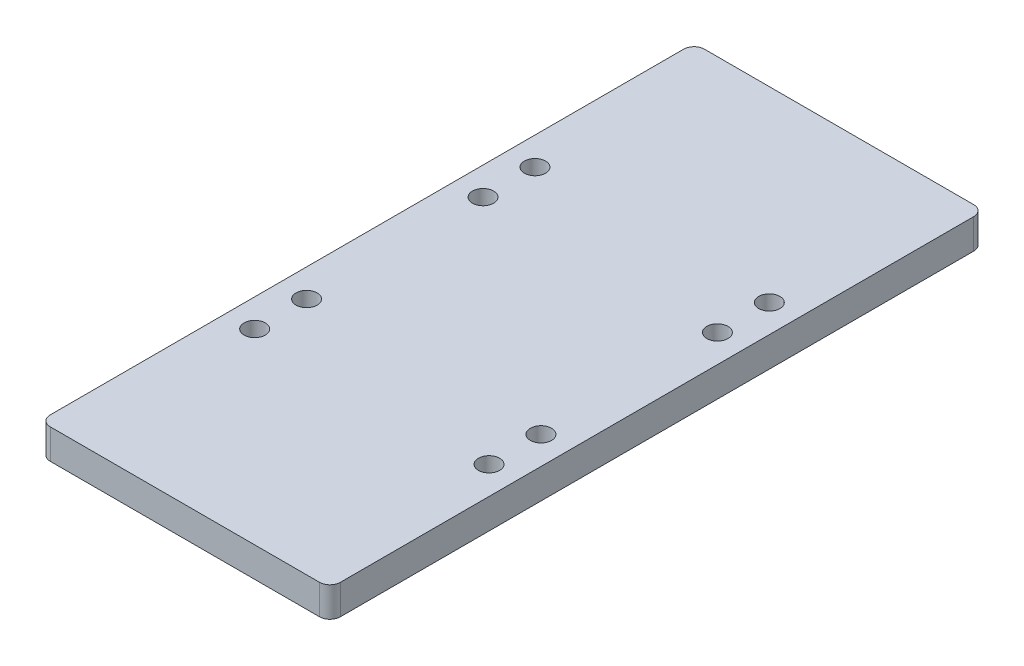
from build123d import *

# Parameters (mm, degrees)
SKETCH1_W                  = 70.946
SKETCH1_H                  = 160
BOSS_EXTRUDE1_DEPTH        = 7.3152
F_6_0_204_DIAMETER_HOLE1_D = 5.1816
FILLET1_R                  = 2.54
MIRROR3_COPY_1_D           = 5.1816


with BuildPart() as part:
    # Sketch1 → Boss-Extrude1 (new body)
    with BuildSketch(Plane(origin=(0, 0, 0), x_dir=(1, 0, 0), z_dir=(0, 1, 0))):
        Rectangle(SKETCH1_W, SKETCH1_H)
    extrude(amount=BOSS_EXTRUDE1_DEPTH)

    # 6 _0.204_ Diameter Hole1 (through all)
    with Locations(Plane(origin=(-28.6626, 7.3152, 34.28), x_dir=(0, 0, 1), z_dir=(0, 1, 0))):
        with Locations((0, 0), (-12.7, 0)):
            f_6_0_204_diameter_hole1 = Hole(F_6_0_204_DIAMETER_HOLE1_D / 2)

    # Mirror2: 6 _0.204_ Diameter Hole1 across plane
    add(f_6_0_204_diameter_hole1.mirror(Plane(origin=(0, 0, 0), x_dir=(0, 0, 1), z_dir=(1, 0, 0))), mode=Mode.SUBTRACT)

    # Fillet1
    fillet1_edges = [part.edges().sort_by_distance(p)[0] for p in [
        (-35.473, 3.6576, -80),
        (35.473, 3.6576, -80),
        (35.473, 3.6576, 80),
        (-35.473, 3.6576, 80),
    ]]
    fillet(fillet1_edges, radius=FILLET1_R)

    # Mirror3: 6 _0.204_ Diameter Hole1 across plane
    add(f_6_0_204_diameter_hole1.mirror(Plane.XY), mode=Mode.SUBTRACT)

    # Mirror3 copy 1 (through all)
    with Locations(Plane(origin=(28.6626, 7.3152, -34.28), x_dir=(0, 0, -1), z_dir=(0, 1, 0))):
        with Locations((0, 0), (-12.7, 0)):
            Hole(MIRROR3_COPY_1_D / 2)


solid = part.part
